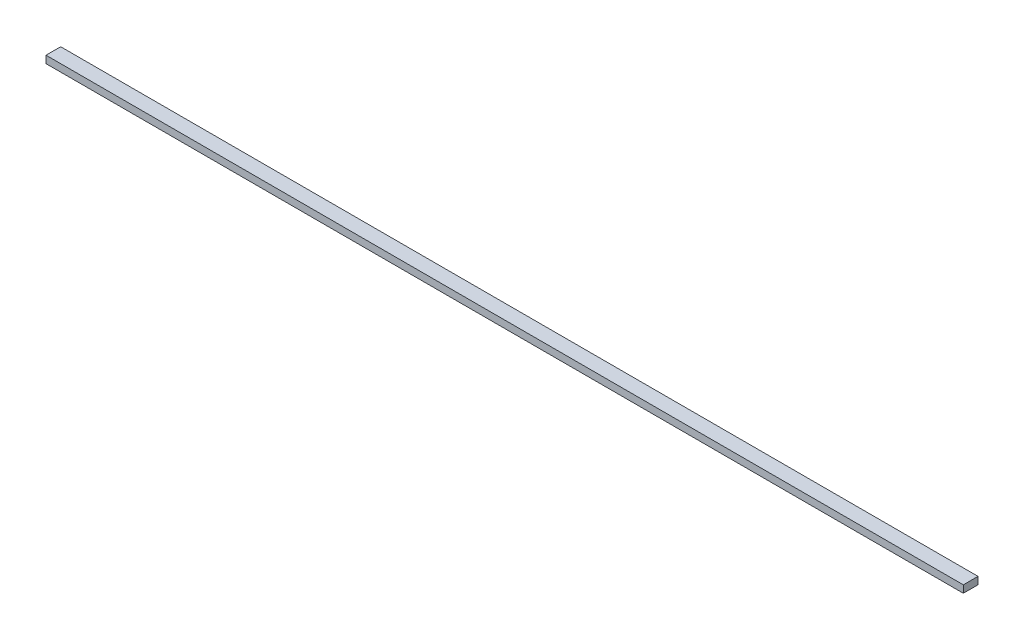
from build123d import *

# Parameters (mm, degrees)
SKETCH1_W           = 1250
SKETCH1_H           = 20
BOSS_EXTRUDE1_DEPTH = 10


with BuildPart() as part:
    # Sketch1 → Boss-Extrude1 (new body)
    with BuildSketch(Plane(origin=(0, 0, 0), x_dir=(1, 0, 0), z_dir=(0, 1, 0))):
        Rectangle(SKETCH1_W, SKETCH1_H)
    extrude(amount=BOSS_EXTRUDE1_DEPTH)


solid = part.part
